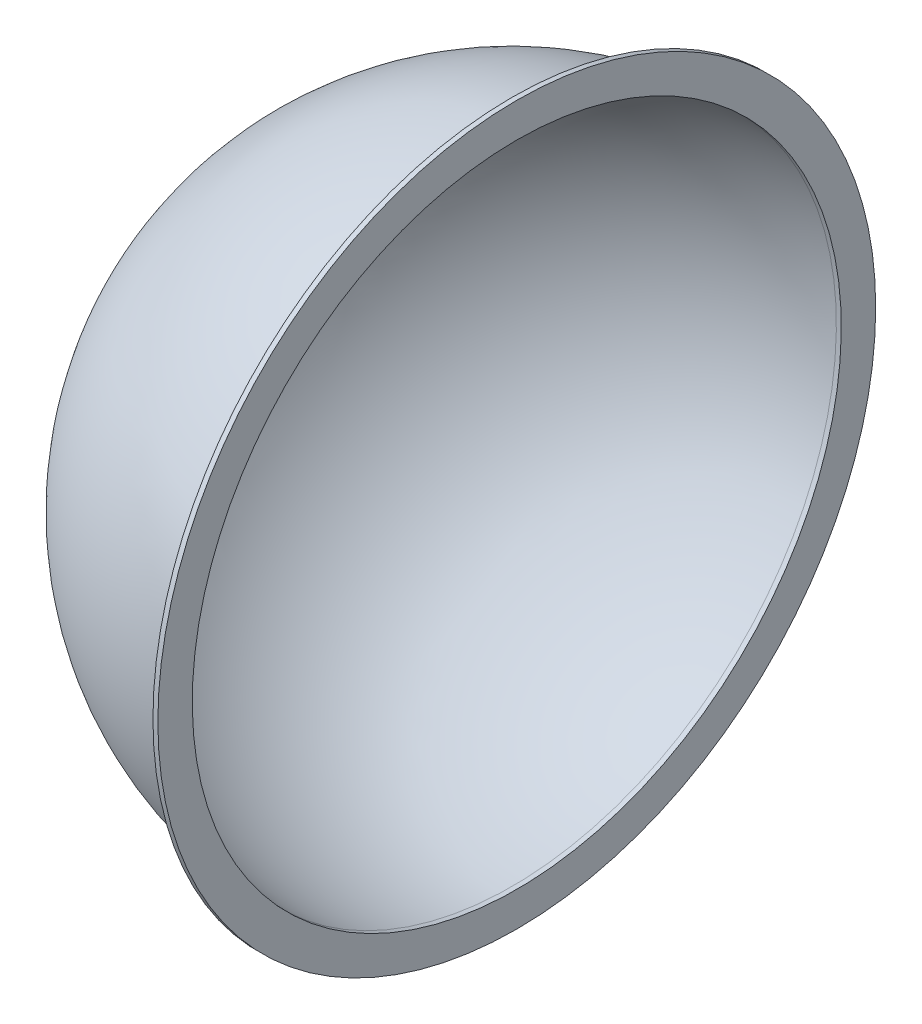
from build123d import *


with BuildPart() as part:
    # Sketch1 → Revolve1 (revolve)
    with BuildSketch(Plane.XY):
        with BuildLine():
            Line((-22.225, 138.1125), (-22.225, 149.225))
            Line((-22.225, 149.225), (-23.8125, 149.225))
            Line((-23.8125, 149.225), (-23.8125, 139.7))
            ThreePointArc((-23.8125, 139.7), (-99.022145014, 108.547145014), (-130.175, 33.3375))
            Line((-130.175, 33.3375), (-128.5875, 33.3375))
            ThreePointArc((-128.5875, 33.3375), (-97.899612999, 107.424612999), (-23.8125, 138.1125))
            Line((-23.8125, 138.1125), (-22.225, 138.1125))
        make_face()
    revolve(axis=Axis((-22.225, 33.3375, 0), (-1, 0, 0)))


solid = part.part
